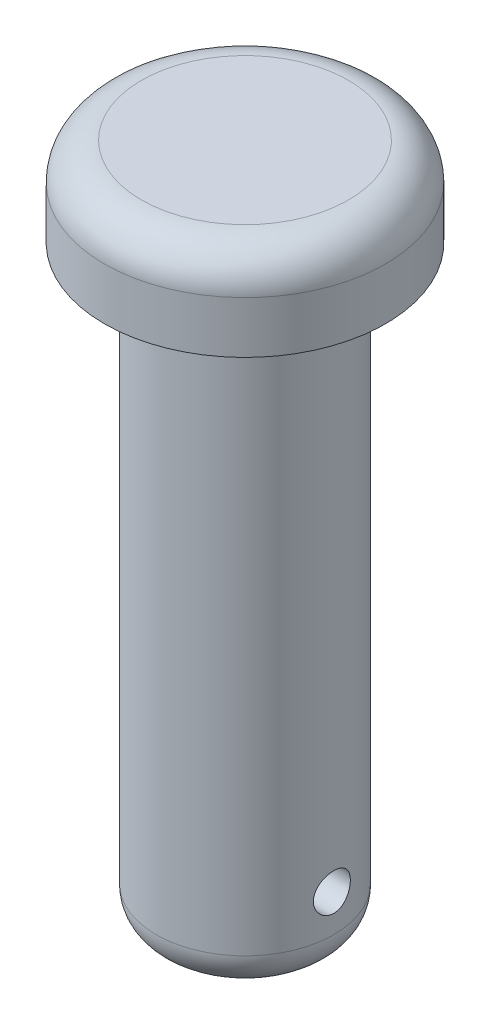
from build123d import *

# Parameters (mm, degrees)
SKETCH5_R          = 2.5
CUT_EXTRUDE1_DEPTH = 35


with BuildPart() as part:
    # Sketch1 → Revolve3 (revolve)
    with BuildSketch(Plane.XY):
        with BuildLine():
            Line((0, 52), (14, 52))
            ThreePointArc((14, 52), (17.535533906, 50.535533906), (19, 47))
            Line((19, 47), (19, 40))
            Line((19, 40), (12, 40))
            Line((12, 40), (12, -35))
            ThreePointArc((12, -35), (10.535533906, -38.535533906), (7, -40))
            Line((7, -40), (0, -40))
            Line((0, -40), (0, 52))
        make_face()
    revolve(axis=Axis((0, 87.076923077, 0), (0, -1, 0)))

    # Sketch5 → Cut-Extrude1 (cut, symmetric)
    with BuildSketch(Plane(origin=(0, 0, 0), x_dir=(0, 0, -1), z_dir=(1, 0, 0))):
        with Locations((0, -30)):
            Circle(SKETCH5_R)
    extrude(amount=CUT_EXTRUDE1_DEPTH, both=True, mode=Mode.SUBTRACT)


solid = part.part
